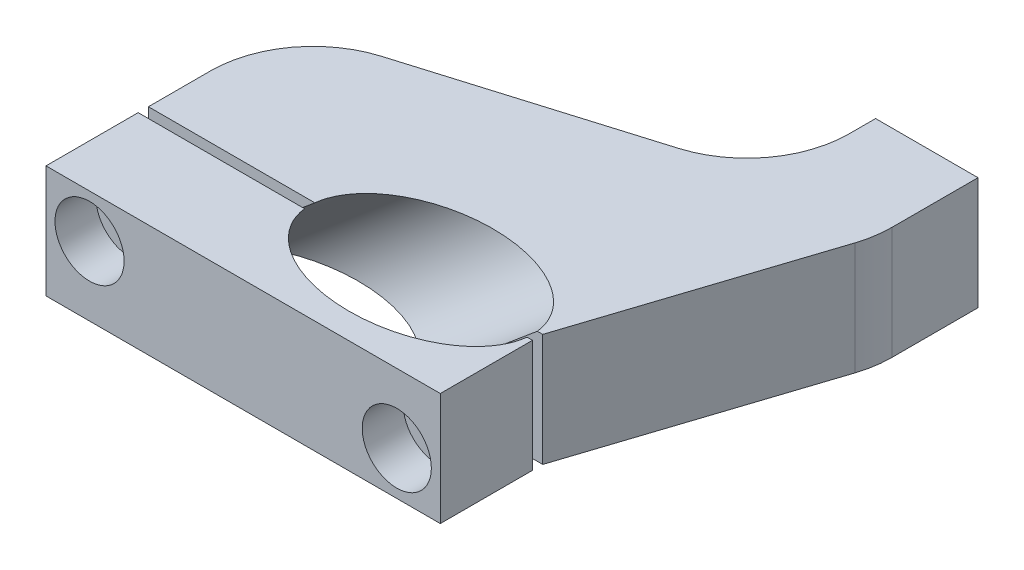
from build123d import *

# Parameters (mm, degrees)
BOSS_EXTRU_1_DEPTH      = 22
ESQUISSE1_W             = 77
ESQUISSE1_H             = 18
BOSS_EXTRU_1_2_DEPTH    = 22
ESQUISSE4_R             = 4
ENL_V_MAT_EXTRU_1_DEPTH = 22
CONG_1_R                = 20
CONG_2_R                = 20
ESQUISSE8_R             = 6.75
ENL_V_MAT_EXTRU_2_DEPTH = 8
ESQUISSE9_R             = 4
ENL_V_MAT_EXTRU_3_DEPTH = 30
CONG_3_R                = 20


with BuildPart() as part:
    # Esquisse1 → Boss.-Extru.1 (new body)
    with BuildSketch(Plane(origin=(0, 0, 0), x_dir=(1, 0, 0), z_dir=(0, 1, 0))):
        Polygon((-28, 1), (49, 1), (65, 50), (65, 70), (45, 70), (45, 50), (-28, 28), align=None)
    extrude(amount=BOSS_EXTRU_1_DEPTH)


with BuildPart() as body_2:
    # Esquisse1 → Boss.-Extru.1 2 (new body)
    with BuildSketch(Plane(origin=(0, 0, 0), x_dir=(1, 0, 0), z_dir=(0, 1, 0))):
        with Locations((10.5, -10)):
            Rectangle(ESQUISSE1_W, ESQUISSE1_H)
    extrude(amount=BOSS_EXTRU_1_2_DEPTH)


with BuildPart() as enl_vement_de_mati_re_r_volution1_tool:
    # Esquisse3 → Enlèvement de matière-Révolution1 (revolve)
    with BuildSketch(Plane.XY):
        Polygon((-42.132444372, -35.353318533), (42.132444372, 35.353318533), (33.133417836, 46.077940736), (-51.131470907, -24.628696329), align=None)
    revolve(axis=Axis((-42.132444372, -35.353318533, 0), (0.766044443, 0.64278761, 0)))


with BuildPart() as part_1:
    add(part.part)

    # Enlèvement de matière-Révolution1: cut by enl_vement_de_mati_re_r_volution1_tool
    add(enl_vement_de_mati_re_r_volution1_tool.part, mode=Mode.SUBTRACT)

    # Esquisse4 → Enlèv. mat.-Extru.1 (cut)
    with BuildSketch(Plane(origin=(0, 0, -70), x_dir=(-1, 0, 0), z_dir=(0, 0, -1))):
        with Locations((-55, 11)):
            Circle(ESQUISSE4_R)
    extrude(amount=-ENL_V_MAT_EXTRU_1_DEPTH, mode=Mode.SUBTRACT)

    # Congé1
    cong_1_edges = [part_1.edges().sort_by_distance(p)[0] for p in [
        (45, 11, -50),
    ]]
    fillet(cong_1_edges, radius=CONG_1_R)

    # Congé2
    cong_2_edges = [part_1.edges().sort_by_distance(p)[0] for p in [
        (65, 11, -50),
    ]]
    fillet(cong_2_edges, radius=CONG_2_R)


with BuildPart() as body_2_1:
    add(body_2.part)

    # Enlèvement de matière-Révolution1: cut by enl_vement_de_mati_re_r_volution1_tool
    add(enl_vement_de_mati_re_r_volution1_tool.part, mode=Mode.SUBTRACT)

    # Esquisse8 → Enlèv. mat.-Extru.2 (cut)
    with BuildSketch(Plane.XY.offset(19)):
        with Locations((40.5, 8.5)):
            Circle(ESQUISSE8_R)
        with Locations((-19.5, 13.5)):
            Circle(ESQUISSE8_R)
    extrude(amount=-ENL_V_MAT_EXTRU_2_DEPTH, mode=Mode.SUBTRACT)


with BuildPart() as enl_v_mat_extru_3_tool:
    # Esquisse9 → Enlèv. mat.-Extru.3 (new body)
    with BuildSketch(Plane.XY.offset(11)):
        with Locations((-19.5, 13.5)):
            Circle(ESQUISSE9_R)
        with Locations((40.5, 8.5)):
            Circle(ESQUISSE9_R)
    extrude(amount=-ENL_V_MAT_EXTRU_3_DEPTH)


with BuildPart() as part_2:
    add(part_1.part)

    # Enlèv. mat.-Extru.3: cut by enl_v_mat_extru_3_tool
    add(enl_v_mat_extru_3_tool.part, mode=Mode.SUBTRACT)

    # Congé3
    cong_3_edges = [part_2.edges().sort_by_distance(p)[0] for p in [
        (-28, 11, -28),
    ]]
    fillet(cong_3_edges, radius=CONG_3_R)


with BuildPart() as body_2_2:
    add(body_2_1.part)

    # Enlèv. mat.-Extru.3: cut by enl_v_mat_extru_3_tool
    add(enl_v_mat_extru_3_tool.part, mode=Mode.SUBTRACT)


solid = Compound([part_2.part, body_2_2.part])
